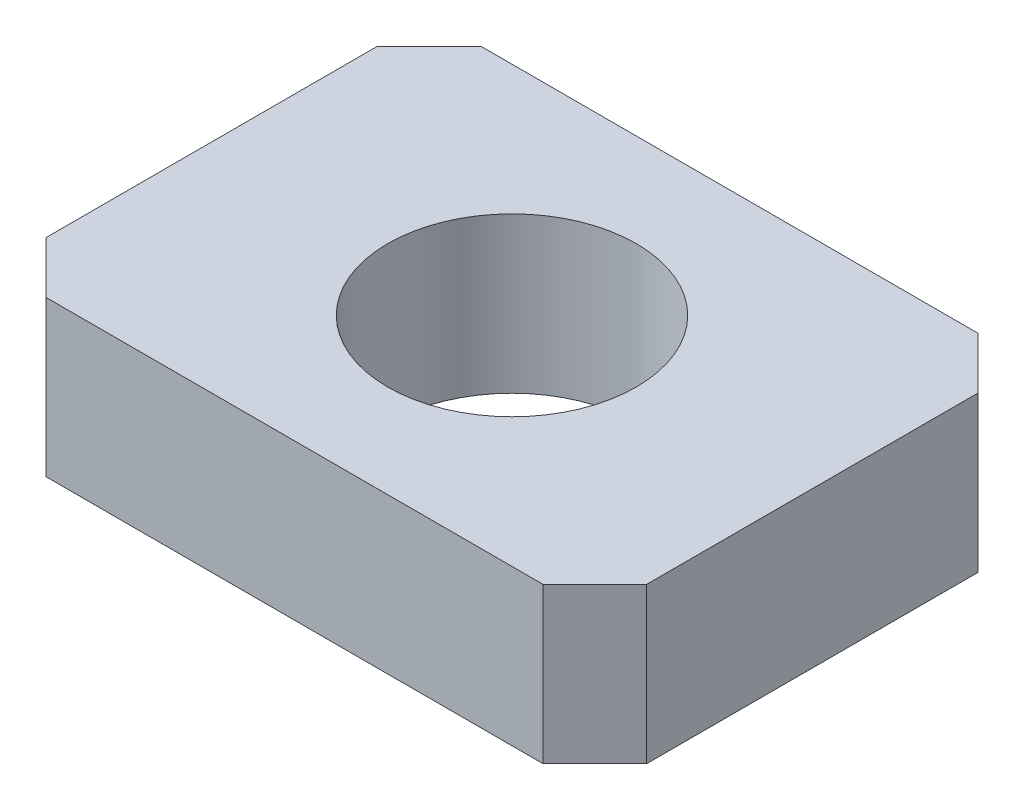
from build123d import *

# Parameters (mm, degrees)
SKETCH1_W           = 5.8
SKETCH1_H           = 4.2
SKETCH1_R           = 1.2
BOSS_EXTRUDE1_DEPTH = 1.5
CHAMFER1_SIZE       = 0.5


with BuildPart() as part:
    # Sketch1 → Boss-Extrude1 (new body)
    with BuildSketch(Plane(origin=(0, 0, 0), x_dir=(1, 0, 0), z_dir=(0, 1, 0))):
        Rectangle(SKETCH1_W, SKETCH1_H)
        Circle(SKETCH1_R, mode=Mode.SUBTRACT)
    extrude(amount=BOSS_EXTRUDE1_DEPTH)

    # Chamfer1
    chamfer1_edges = [part.edges().sort_by_distance(p)[0] for p in [
        (2.9, 0.75, 2.1),
        (-2.9, 0.75, 2.1),
        (-2.9, 0.75, -2.1),
        (2.9, 0.75, -2.1),
    ]]
    chamfer(chamfer1_edges, length=CHAMFER1_SIZE)


solid = part.part
